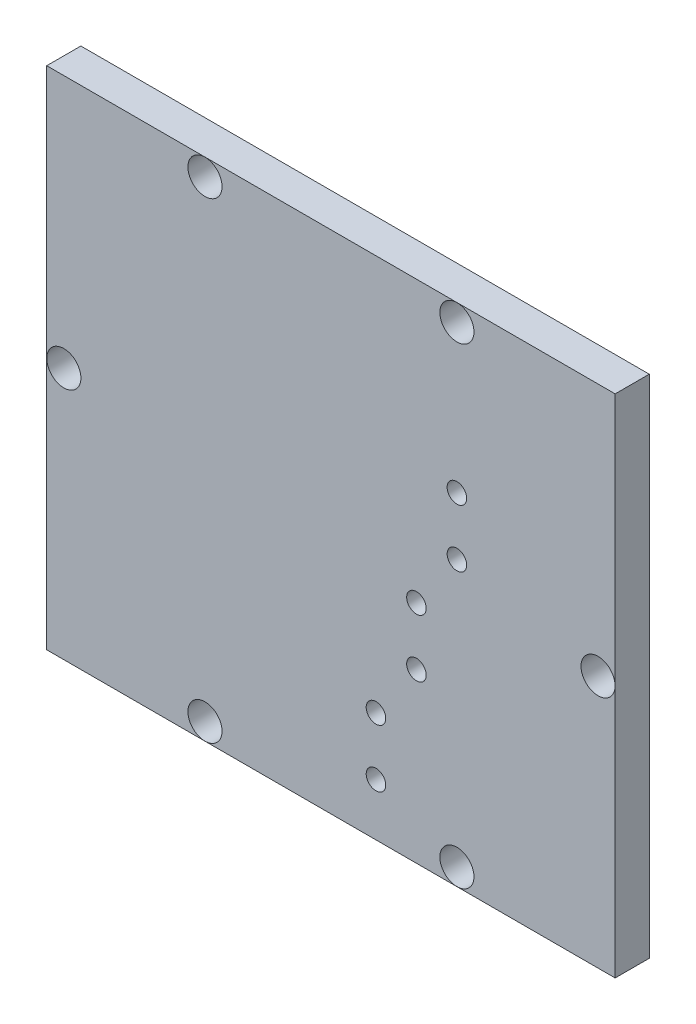
from build123d import *

# Parameters (mm, degrees)
SKETCH1_W           = 158.75
SKETCH1_H           = 141.2875
BOSS_EXTRUDE1_DEPTH = 9.525
SKETCH2_R           = 4.7625
SKETCH2_R_2         = 2.7305
CUT_EXTRUDE7_DEPTH  = 9.525


with BuildPart() as part:
    # Sketch1 → Boss-Extrude1 (new body)
    with BuildSketch(Plane.XY):
        with Locations((79.375, 70.64375)):
            Rectangle(SKETCH1_W, SKETCH1_H)
    extrude(amount=BOSS_EXTRUDE1_DEPTH)

    # Sketch2 → Cut-Extrude7 (cut)
    with BuildSketch(Plane.XY.offset(9.525)):
        with Locations((4.7752, 70.503604532)):
            Circle(SKETCH2_R)
        with Locations((153.9748, 70.64375)):
            Circle(SKETCH2_R)
        with Locations((44.196, 136.5123)):
            Circle(SKETCH2_R)
        with Locations((114.554, 136.5123)):
            Circle(SKETCH2_R)
        with Locations((44.196, 4.7752)):
            Circle(SKETCH2_R)
        with Locations((114.554, 4.7752)):
            Circle(SKETCH2_R)
        with Locations((91.948, 14.605)):
            Circle(SKETCH2_R_2)
        with Locations((91.948, 30.734)):
            Circle(SKETCH2_R_2)
        with Locations((103.251, 46.863)):
            Circle(SKETCH2_R_2)
        with Locations((103.251, 62.992)):
            Circle(SKETCH2_R_2)
        with Locations((114.554, 79.121)):
            Circle(SKETCH2_R_2)
        with Locations((114.554, 95.25)):
            Circle(SKETCH2_R_2)
    extrude(amount=-CUT_EXTRUDE7_DEPTH, mode=Mode.SUBTRACT)


solid = part.part
